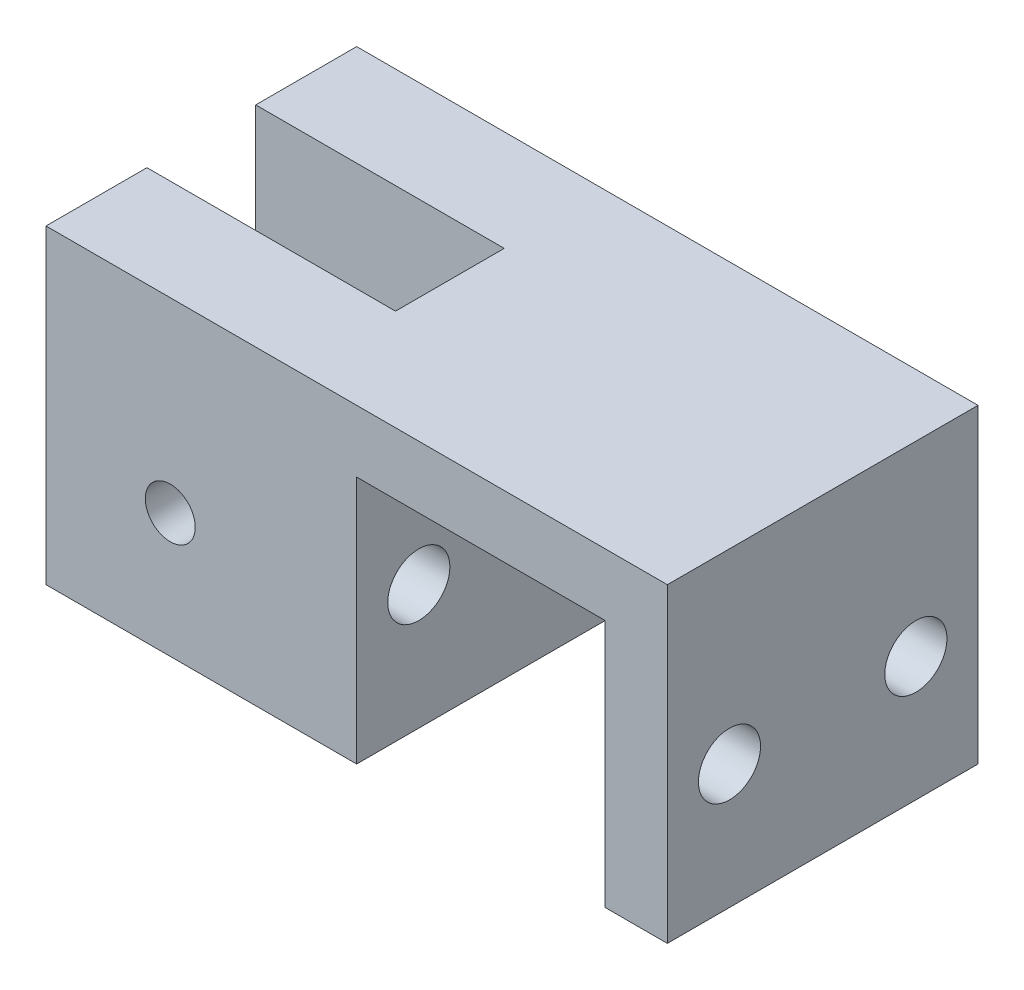
from build123d import *

# Parameters (mm, degrees)
BOSS_EXTRUDE1_DEPTH             = 15.875
SKETCH2_W                       = 25.4
SKETCH2_H                       = 11.1125
CUT_EXTRUDE1_DEPTH              = 32.75
F_1_4_0_25_DIAMETER_HOLE1_D     = 6.35
F_1_4_0_25_DIAMETER_HOLE1_DEPTH = 44.45
F_1_4_0_25_DIAMETER_HOLE1_TIP   = 1.907732465
F_10_CLEARANCE_HOLE1_D          = 5.1054


with BuildPart() as part:
    # Sketch1 → Boss-Extrude1 (new body, symmetric)
    with BuildSketch(Plane.XY):
        Polygon((0, 0), (0, 25.4), (25.4, 25.4), (25.4, 0), (31.75, 0), (31.75, 31.75), (-31.75, 31.75), (-31.75, 0), align=None)
    extrude(amount=BOSS_EXTRUDE1_DEPTH, both=True)

    # Sketch2 → Cut-Extrude1 (cut, through all)
    with BuildSketch(Plane(origin=(0, 31.75, 0), x_dir=(1, 0, 0), z_dir=(0, 1, 0))):
        with Locations((-19.05, 0)):
            Rectangle(SKETCH2_W, SKETCH2_H)
    extrude(amount=-CUT_EXTRUDE1_DEPTH, mode=Mode.SUBTRACT)

    # 1/4 (0.25) Diameter Hole1
    with Locations(Plane(origin=(31.75, 0, 0), x_dir=(0, 0, -1), z_dir=(1, 0, 0))):
        with Locations((-9.525, 12.7), (9.525, 12.7)):
            Hole(F_1_4_0_25_DIAMETER_HOLE1_D / 2, depth=F_1_4_0_25_DIAMETER_HOLE1_DEPTH)
            with Locations((0, 0, -(F_1_4_0_25_DIAMETER_HOLE1_DEPTH + F_1_4_0_25_DIAMETER_HOLE1_TIP / 2))):  # 118° drill point
                Cone(0, F_1_4_0_25_DIAMETER_HOLE1_D / 2, F_1_4_0_25_DIAMETER_HOLE1_TIP, mode=Mode.SUBTRACT)

    # #10 Clearance Hole1 (through all)
    with Locations(Plane.XY.offset(15.875)):
        with Locations((-19.05, 12.7)):
            Hole(F_10_CLEARANCE_HOLE1_D / 2)


solid = part.part
